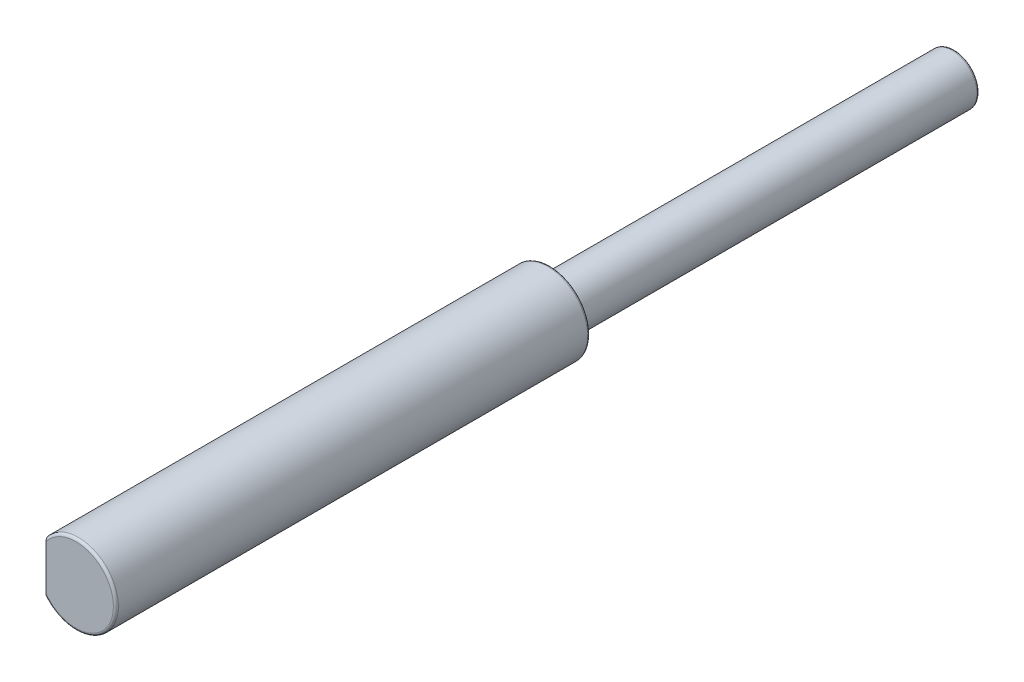
from build123d import *

# Parameters (mm, degrees)
SKETCH1_R               = 2.5
EXTRUDE1_DEPTH          = 40.5
SKETCH3_R               = 4
BOSS_EXTRUDE1_DEPTH     = 47.5
FILLET1_R               = 0.25
CUT_EXTRUDE1_DEPTH      = 3
CUT_EXTRUDE1_DEPTH_BACK = 3


with BuildPart() as part:
    # Sketch1 → Extrude1 (new body)
    with BuildSketch(Plane.XY):
        Circle(SKETCH1_R)
    extrude(amount=EXTRUDE1_DEPTH)

    # Sketch3 → Boss-Extrude1 (add)
    with BuildSketch(Plane.XY.offset(40.5)):
        Circle(SKETCH3_R)
    extrude(amount=BOSS_EXTRUDE1_DEPTH)

    # Fillet1
    fillet1_edges = [part.edges().sort_by_distance(p)[0] for p in [
        (-4, 0, 88),
        (-4, 0, 40.5),
        (-2.5, 0, 0),
    ]]
    fillet(fillet1_edges, radius=FILLET1_R)

    # Sketch2 → Cut-Extrude1 (cut, two sides: drawn at the far end of the back side and taken through both)
    with BuildSketch(Plane(origin=(0, 0, 0), x_dir=(1, 0, 0), z_dir=(0, 1, 0)).offset(-CUT_EXTRUDE1_DEPTH_BACK)):
        with BuildLine():
            Line((-3, -88), (-5, -88))
            Line((-5, -88), (-5, -73))
            Line((-5, -73), (-4, -73))
            ThreePointArc((-4, -73), (-3.292893219, -73.292893219), (-3, -74))
            Line((-3, -74), (-3, -88))
        make_face()
    extrude(amount=CUT_EXTRUDE1_DEPTH + CUT_EXTRUDE1_DEPTH_BACK, mode=Mode.SUBTRACT)


solid = part.part
